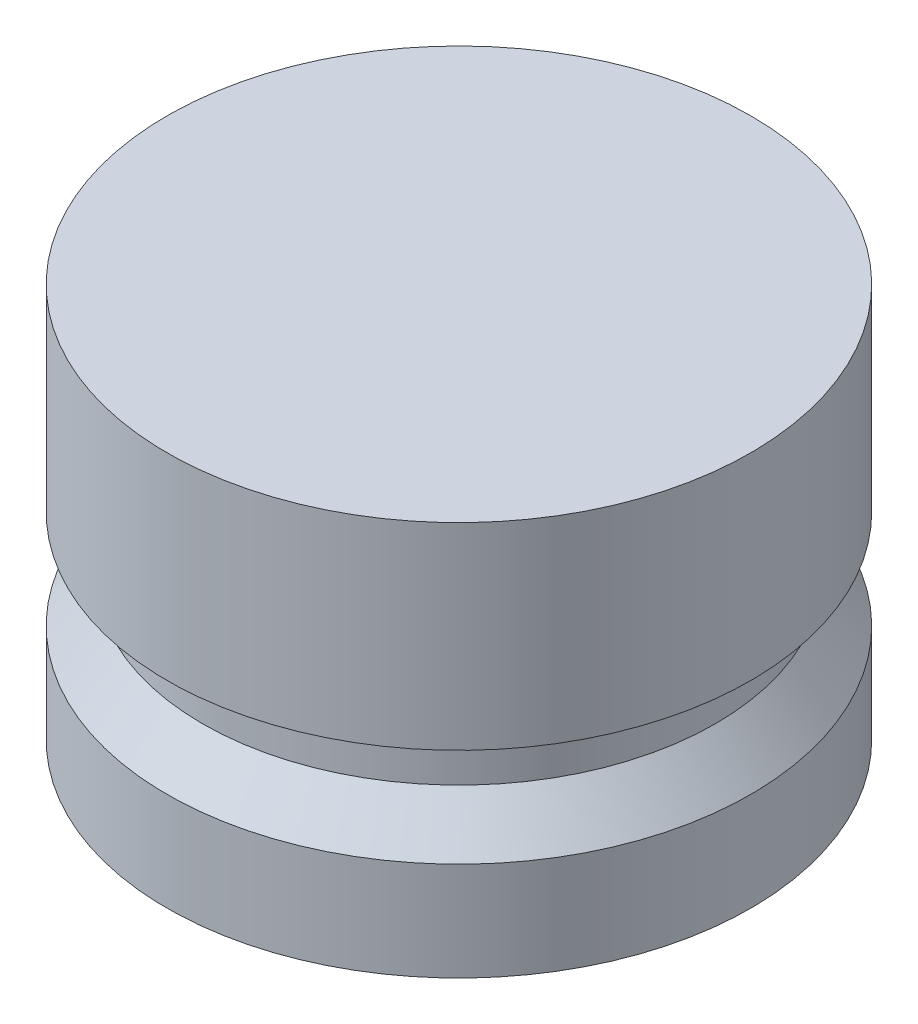
from build123d import *


with BuildPart() as part:
    # Sketch1 → Revolve1 (revolve)
    with BuildSketch(Plane.XY):
        Polygon((0, 0), (-9.398, 0), (-9.398, 3.175), (-8.255, 4.572), (-8.255, 6.35), (-9.398, 6.35), (-9.398, 12.7), (0, 12.7), align=None)
    revolve(axis=Axis((0, 0, 0), (0, 1, 0)))


solid = part.part
